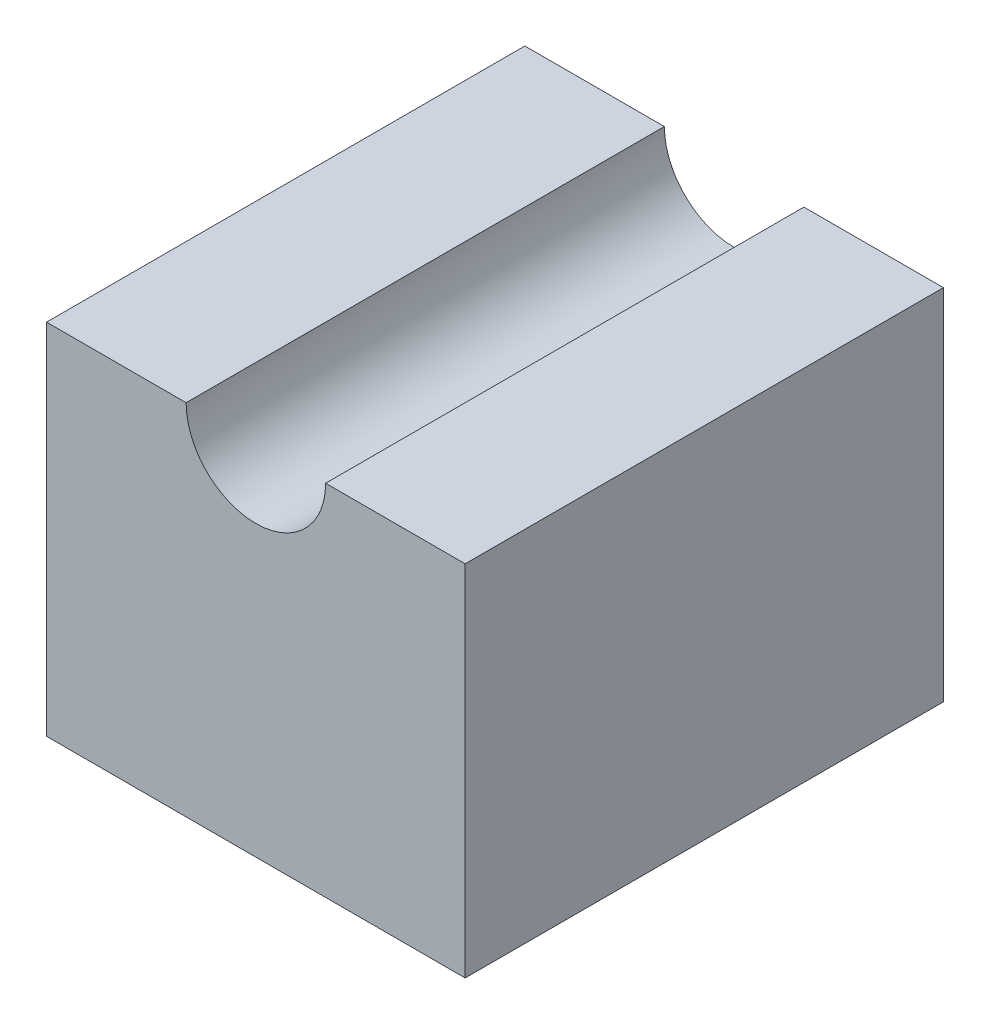
from build123d import *

# Parameters (mm, degrees)
BOSS_EXTRUDE1_DEPTH = 50.8


with BuildPart() as part:
    # Sketch1 → Boss-Extrude1 (new body)
    with BuildSketch(Plane.XY):
        with BuildLine():
            Line((0, 0), (14.82, 0))
            ThreePointArc((14.82, 0), (22.23, -7.41), (29.64, 0))
            Line((29.64, 0), (44.46, 0))
            Line((44.46, 0), (44.46, -38.1))
            Line((44.46, -38.1), (0, -38.1))
            Line((0, -38.1), (0, 0))
        make_face()
    extrude(amount=BOSS_EXTRUDE1_DEPTH)


solid = part.part
